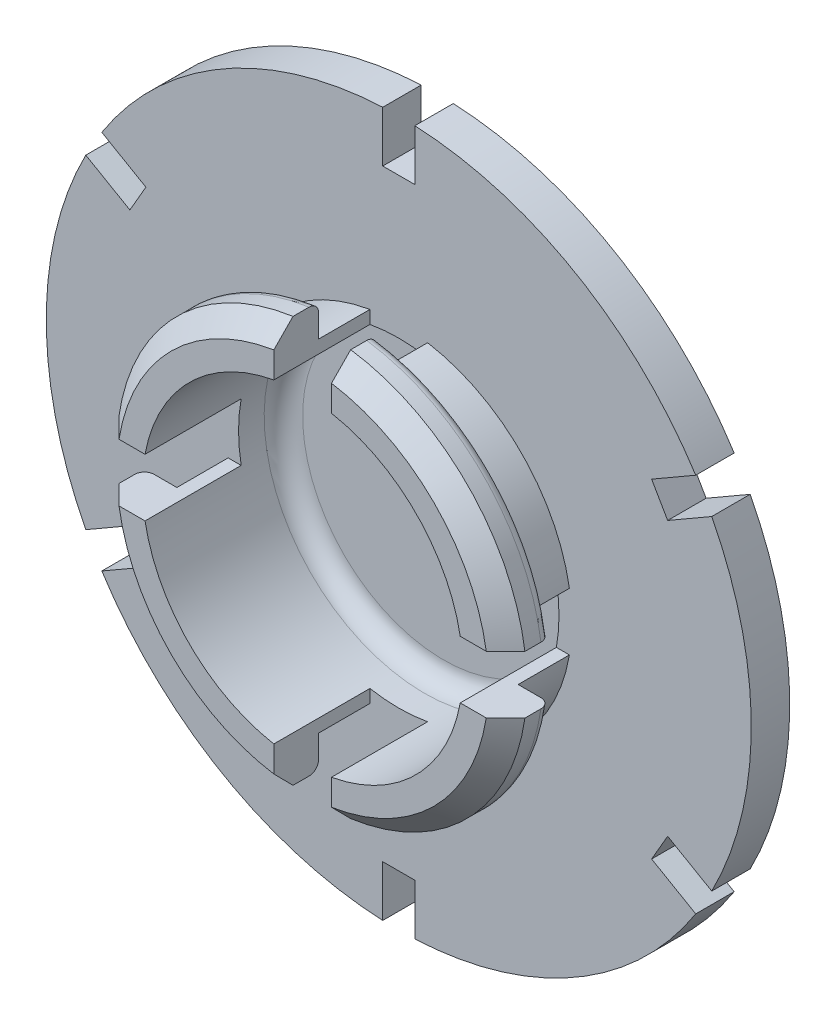
from build123d import *

# Parameters (mm, degrees)
CHAMFER1_SIZE      = 1.5
FILLET1_R          = 0.75
SKETCH3_W          = 2.5
SKETCH3_H          = 4
CUT_EXTRUDE2_DEPTH = 10
CIRPATTERN1_COUNT  = 6
SKETCH4_W          = 4.5
SKETCH4_H          = 5
CUT_EXTRUDE3_DEPTH = 7.5
CIRPATTERN2_COUNT  = 4
CUT_EXTRUDE4_DEPTH = 6.5
FILLET2_R          = 1.5


with BuildPart() as part:
    # Sketch1 → Revolve1 (revolve)
    with BuildSketch(Plane(origin=(0, 0, 0), x_dir=(1, 0, 0), z_dir=(0, 1, 0))):
        with BuildLine():
            Line((0, 11), (0, 14.5))
            ThreePointArc((0, 14.5), (-2.753354767, 14.446616368), (-5.50257096, 14.286545711))
            ThreePointArc((-5.50257096, 14.286545711), (-6.315992081, 14.971589773), (-6.996732248, 14.154563389))
            ThreePointArc((-6.996732248, 14.154563389), (-15.357461634, 12.819934912), (-23.5, 10.5))
            Line((-23.5, 10.5), (-27.5, 10.5))
            Line((-27.5, 10.5), (-27.5, 7.5))
            Line((-27.5, 7.5), (-13.5, 7.5))
            Line((-13.5, 7.5), (-13.5, 3.5))
            Line((-13.5, 3.5), (-16, 3.5))
            Line((-16, 3.5), (-16, 0))
            Line((-16, 0), (-12.5, 0))
            Line((-12.5, 0), (-12.5, 11))
            Line((-12.5, 11), (0, 11))
        make_face()
    revolve(axis=Axis((0, 0, -11), (0, 0, 1)))

    # Chamfer1
    chamfer1_edges = [part.edges().sort_by_distance(p)[0] for p in [
        (16, 0, 0),
    ]]
    chamfer(chamfer1_edges, length=CHAMFER1_SIZE)

    # Fillet1
    fillet1_edges = [part.edges().sort_by_distance(p)[0] for p in [
        (16, 0, -3.5),
    ]]
    fillet(fillet1_edges, radius=FILLET1_R)

    # Sketch3 → Cut-Extrude2 (cut)
    with BuildSketch(Plane(origin=(0, 0, -10.5), x_dir=(-1, 0, 0), z_dir=(0, 0, -1))):
        with Locations((0, 25.5)):
            Rectangle(SKETCH3_W, SKETCH3_H)
    cut_extrude2 = extrude(amount=-CUT_EXTRUDE2_DEPTH, mode=Mode.SUBTRACT)

    # CirPattern1: Cut-Extrude2 ×6 about axis
    cirpattern1_axis = Axis((0, 0, 0), (0, 0, 1))
    for i in range(1, CIRPATTERN1_COUNT):
        add(cut_extrude2.rotate(cirpattern1_axis, i * 360 / CIRPATTERN1_COUNT), mode=Mode.SUBTRACT)

    # Sketch4 → Cut-Extrude3 (cut)
    with BuildSketch(Plane.XY):
        with Locations((0, 14.164854804)):
            Rectangle(SKETCH4_W, SKETCH4_H)
    cut_extrude3 = extrude(amount=-CUT_EXTRUDE3_DEPTH, mode=Mode.SUBTRACT)

    # CirPattern2: Cut-Extrude3 ×4 about axis
    cirpattern2_axis = Axis((0, 0, 0), (0, 0, 1))
    for i in range(1, CIRPATTERN2_COUNT):
        add(cut_extrude3.rotate(cirpattern2_axis, i * 360 / CIRPATTERN2_COUNT), mode=Mode.SUBTRACT)

    # Sketch7 → Cut-Extrude4 (cut)
    with BuildSketch(Plane.XY.offset(-20)):
        with BuildLine():
            ThreePointArc((4.638251781, -1.093543849), (4.430429856, -1.030750621), (4.340758353, -0.833033743))
            Line((4.340758353, -0.833033743), (4.340758353, 2.712309027))
            ThreePointArc((4.340758353, 2.712309027), (4.332409956, 2.769489996), (4.308061721, 2.821897271))
            ThreePointArc((4.308061721, 2.821897271), (2.814090515, 4.313165262), (0.847346777, 5.079813327))
            ThreePointArc((0.847346777, 5.079813327), (0.644632707, 5.023986449), (0.556213438, 4.833220447))
            Line((0.556213438, 4.833220447), (0.556213438, 0.537603267))
            ThreePointArc((0.556213438, 0.537603267), (0.629436743, 0.360826572), (0.806213438, 0.287603267))
            Line((0.806213438, 0.287603267), (2.127747708, 0.287603267))
            ThreePointArc((2.127747708, 0.287603267), (2.330633642, 0.183676186), (2.364836834, -0.041698351))
            Line((2.364836834, -0.041698351), (1.021733544, -4.057192539))
            ThreePointArc((1.021733544, -4.057192539), (0.838741439, -4.415352746), (0.588166365, -4.729958814))
            ThreePointArc((0.588166365, -4.729958814), (0.528098213, -4.94034301), (0.670889871, -5.106114646))
            ThreePointArc((0.670889871, -5.106114646), (1.416296911, -4.951424347), (2.130755508, -4.688537188))
            ThreePointArc((2.130755508, -4.688537188), (2.29005975, -4.465637809), (2.176614299, -4.21625436))
            ThreePointArc((2.176614299, -4.21625436), (1.990654951, -4.001205528), (1.923721931, -3.724896191))
            Line((1.923721931, -3.724896191), (3.177382299, 0.023189278))
            ThreePointArc((3.177382299, 0.023189278), (3.250195264, 0.122056731), (3.3670536, 0.159747984))
            Line((3.3670536, 0.159747984), (3.390758353, 0.159747984))
            ThreePointArc((3.390758353, 0.159747984), (3.53217971, 0.10116934), (3.590758353, -0.040252016))
            Line((3.590758353, -0.040252016), (3.590758353, -2.251748136))
            ThreePointArc((3.590758353, -2.251748136), (3.510105322, -2.879327065), (3.341372441, -3.48915445))
            ThreePointArc((3.341372441, -3.48915445), (3.409611033, -3.687287432), (3.61798399, -3.665063689))
            ThreePointArc((3.61798399, -3.665063689), (4.421362656, -2.640843097), (4.942273369, -1.447906748))
            ThreePointArc((4.942273369, -1.447906748), (4.886376652, -1.188265328), (4.638251781, -1.093543849))
        make_face()
        with BuildLine():
            Line((1.306213438, 1.287603267), (1.306213438, 3.847167755))
            ThreePointArc((1.306213438, 3.847167755), (1.416458205, 4.05445614), (1.649961236, 4.078924849))
            ThreePointArc((1.649961236, 4.078924849), (2.704642405, 3.470577684), (3.552223037, 2.596480598))
            ThreePointArc((3.552223037, 2.596480598), (3.580880599, 2.540535573), (3.590758353, 2.478458753))
            Line((3.590758353, 2.478458753), (3.590758353, 1.287603267))
            ThreePointArc((3.590758353, 1.287603267), (3.517535049, 1.110826572), (3.340758353, 1.037603267))
            Line((3.340758353, 1.037603267), (1.556213438, 1.037603267))
            ThreePointArc((1.556213438, 1.037603267), (1.379436743, 1.110826572), (1.306213438, 1.287603267))
        make_face(mode=Mode.SUBTRACT)
        with BuildLine():
            Line((-0.797954184, -4.055068976), (-0.797954184, 4.055068976))
            ThreePointArc((-0.797954184, 4.055068976), (-0.783159294, 4.139795336), (-0.740525735, 4.21449356))
            Line((-0.740525735, 4.21449356), (-0.578710911, 4.409952319))
            ThreePointArc((-0.578710911, 4.409952319), (-0.52187423, 4.552185793), (-0.558658494, 4.700872334))
            Line((-0.558658494, 4.700872334), (-0.709040192, 4.9440348))
            ThreePointArc((-0.709040192, 4.9440348), (-0.821129216, 5.041433941), (-0.968687841, 5.058077092))
            ThreePointArc((-0.968687841, 5.058077092), (-3.264761681, 3.982942526), (-4.769603106, 1.942520583))
            ThreePointArc((-4.769603106, 1.942520583), (-4.74552292, 1.708714111), (-4.538068974, 1.598223467))
            Line((-4.538068974, 1.598223467), (-3.116940381, 1.598223467))
            ThreePointArc((-3.116940381, 1.598223467), (-2.940163685, 1.671446772), (-2.866940381, 1.848223467))
            Line((-2.866940381, 1.848223467), (-2.866940381, 2.098223467))
            ThreePointArc((-2.866940381, 2.098223467), (-2.940163685, 2.275000163), (-3.116940381, 2.348223467))
            Line((-3.116940381, 2.348223467), (-3.236005997, 2.348223467))
            ThreePointArc((-3.236005997, 2.348223467), (-3.461427681, 2.490125992), (-3.430946118, 2.754742953))
            ThreePointArc((-3.430946118, 2.754742953), (-2.736423133, 3.445575197), (-1.906264678, 3.965621638))
            ThreePointArc((-1.906264678, 3.965621638), (-1.664870796, 3.9519359), (-1.547954184, 3.740302227))
            Line((-1.547954184, 3.740302227), (-1.547954184, 0.625))
            ThreePointArc((-1.547954184, 0.625), (-1.621177489, 0.448223305), (-1.797954184, 0.375))
            Line((-1.797954184, 0.375), (-2.392190445, 0.375))
            ThreePointArc((-2.392190445, 0.375), (-2.56896714, 0.448223305), (-2.642190445, 0.625))
            Line((-2.642190445, 0.625), (-2.642190445, 0.871203604))
            ThreePointArc((-2.642190445, 0.871203604), (-2.71541375, 1.047980299), (-2.892190445, 1.121203604))
            Line((-2.892190445, 1.121203604), (-3.142190445, 1.121203604))
            ThreePointArc((-3.142190445, 1.121203604), (-3.31896714, 1.047980299), (-3.392190445, 0.871203604))
            Line((-3.392190445, 0.871203604), (-3.392190445, -0.871203604))
            ThreePointArc((-3.392190445, -0.871203604), (-3.31896714, -1.047980299), (-3.142190445, -1.121203604))
            Line((-3.142190445, -1.121203604), (-2.892190445, -1.121203604))
            ThreePointArc((-2.892190445, -1.121203604), (-2.71541375, -1.047980299), (-2.642190445, -0.871203604))
            Line((-2.642190445, -0.871203604), (-2.642190445, -0.625))
            ThreePointArc((-2.642190445, -0.625), (-2.56896714, -0.448223305), (-2.392190445, -0.375))
            Line((-2.392190445, -0.375), (-1.797954184, -0.375))
            ThreePointArc((-1.797954184, -0.375), (-1.621177489, -0.448223305), (-1.547954184, -0.625))
            Line((-1.547954184, -0.625), (-1.547954184, -3.740302227))
            ThreePointArc((-1.547954184, -3.740302227), (-1.664870796, -3.9519359), (-1.906264678, -3.965621638))
            ThreePointArc((-1.906264678, -3.965621638), (-2.736423133, -3.445575197), (-3.430946118, -2.754742953))
            ThreePointArc((-3.430946118, -2.754742953), (-3.461427681, -2.490125992), (-3.236005997, -2.348223467))
            Line((-3.236005997, -2.348223467), (-3.116940381, -2.348223467))
            ThreePointArc((-3.116940381, -2.348223467), (-2.940163685, -2.275000163), (-2.866940381, -2.098223467))
            Line((-2.866940381, -2.098223467), (-2.866940381, -1.848223467))
            ThreePointArc((-2.866940381, -1.848223467), (-2.940163685, -1.671446772), (-3.116940381, -1.598223467))
            Line((-3.116940381, -1.598223467), (-4.538068974, -1.598223467))
            ThreePointArc((-4.538068974, -1.598223467), (-4.74552292, -1.708714111), (-4.769603106, -1.942520583))
            ThreePointArc((-4.769603106, -1.942520583), (-3.264761681, -3.982942526), (-0.968687841, -5.058077092))
            ThreePointArc((-0.968687841, -5.058077092), (-0.821129216, -5.041433941), (-0.709040192, -4.9440348))
            Line((-0.709040192, -4.9440348), (-0.558658494, -4.700872334))
            ThreePointArc((-0.558658494, -4.700872334), (-0.52187423, -4.552185793), (-0.578710911, -4.409952319))
            Line((-0.578710911, -4.409952319), (-0.740525735, -4.21449356))
            ThreePointArc((-0.740525735, -4.21449356), (-0.783159294, -4.139795336), (-0.797954184, -4.055068976))
        make_face()
    extrude(amount=CUT_EXTRUDE4_DEPTH, mode=Mode.SUBTRACT)

    # Fillet2
    fillet2_edges = [part.edges().sort_by_distance(p)[0] for p in [
        (12.5, 0, -11),
    ]]
    fillet(fillet2_edges, radius=FILLET2_R)


solid = part.part
